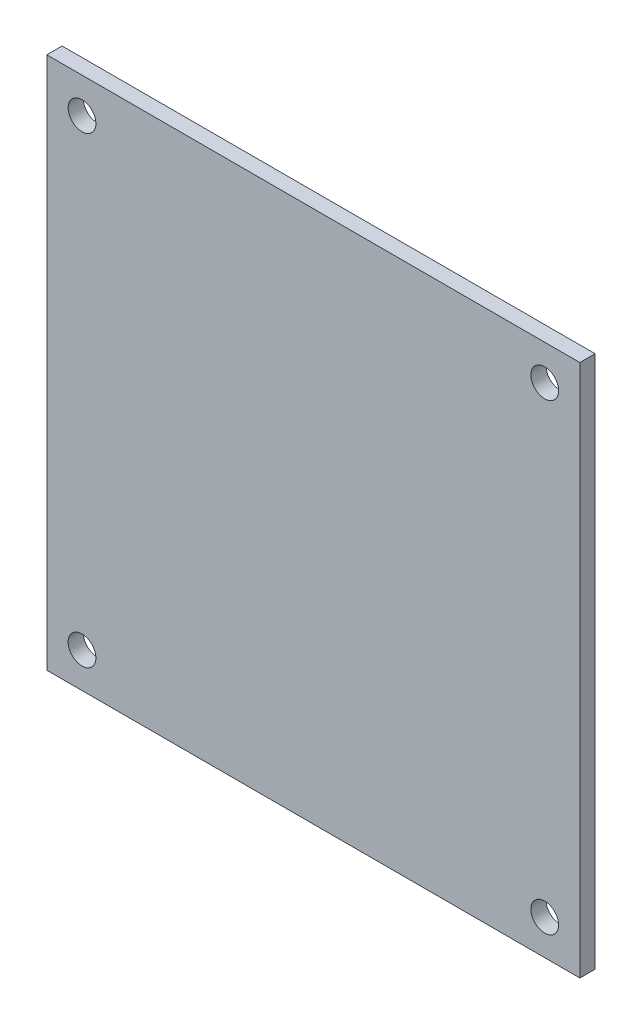
from build123d import *

# Parameters (mm, degrees)
SKETCH_1_W      = 57.595497494
SKETCH_1_H      = 57.595497494
SKETCH_1_R      = 1.5
EXTRUDE_1_DEPTH = 1.65


with BuildPart() as part:
    # 草图1 → 凸台-拉伸1 (new body)
    with BuildSketch(Plane.XY):
        Rectangle(SKETCH_1_W, SKETCH_1_H)
        with Locations((-25, 25)):
            Circle(SKETCH_1_R, mode=Mode.SUBTRACT)
        with Locations((25, 25)):
            Circle(SKETCH_1_R, mode=Mode.SUBTRACT)
        with Locations((-25, -25)):
            Circle(SKETCH_1_R, mode=Mode.SUBTRACT)
        with Locations((25, -25)):
            Circle(SKETCH_1_R, mode=Mode.SUBTRACT)
    extrude(amount=EXTRUDE_1_DEPTH)


solid = part.part
